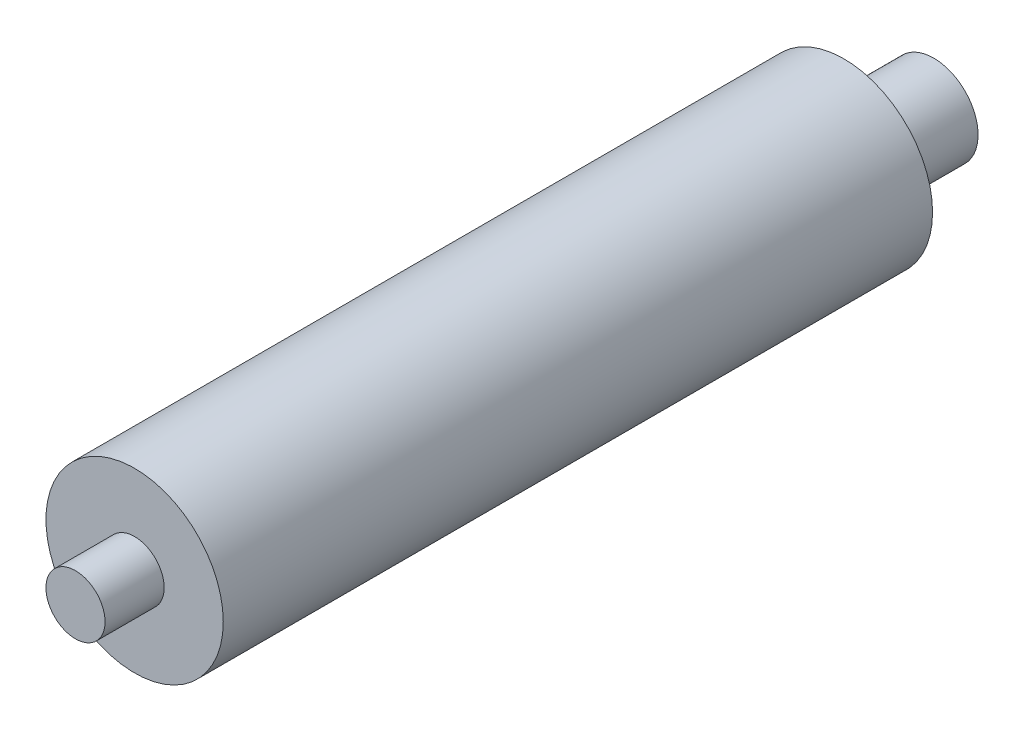
from build123d import *

# Parameters (mm, degrees)
SKETCH1_R           = 9.525
BOSS_EXTRUDE1_DEPTH = 76.2
SKETCH2_R           = 3.175
BOSS_EXTRUDE2_DEPTH = 6.35
SKETCH3_R           = 4.7625
BOSS_EXTRUDE3_DEPTH = 9.652


with BuildPart() as part:
    # Sketch1 → Boss-Extrude1 (new body)
    with BuildSketch(Plane.XY):
        Circle(SKETCH1_R)
    extrude(amount=BOSS_EXTRUDE1_DEPTH)

    # Sketch2 → Boss-Extrude2 (add)
    with BuildSketch(Plane.XY.offset(76.2)):
        Circle(SKETCH2_R)
    extrude(amount=BOSS_EXTRUDE2_DEPTH)

    # Sketch3 → Boss-Extrude3 (add)
    with BuildSketch(Plane(origin=(0, 0, 0), x_dir=(-1, 0, 0), z_dir=(0, 0, -1))):
        Circle(SKETCH3_R)
    extrude(amount=BOSS_EXTRUDE3_DEPTH)


solid = part.part
